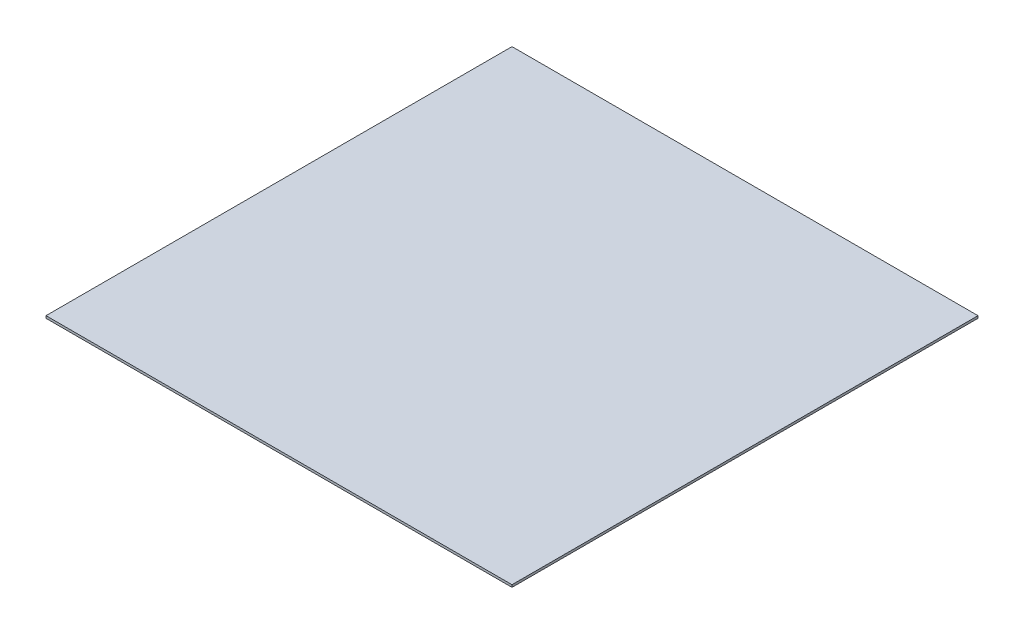
from build123d import *

# Parameters (mm, degrees)
SKETCH1_W           = 2000
SKETCH1_H           = 2000
BOSS_EXTRUDE1_DEPTH = 10


with BuildPart() as part:
    # Sketch1 → Boss-Extrude1 (new body)
    with BuildSketch(Plane(origin=(0, 0, 0), x_dir=(1, 0, 0), z_dir=(0, 1, 0))):
        with Locations((951.391844411, 1046.452148688)):
            Rectangle(SKETCH1_W, SKETCH1_H)
    extrude(amount=BOSS_EXTRUDE1_DEPTH)


solid = part.part
